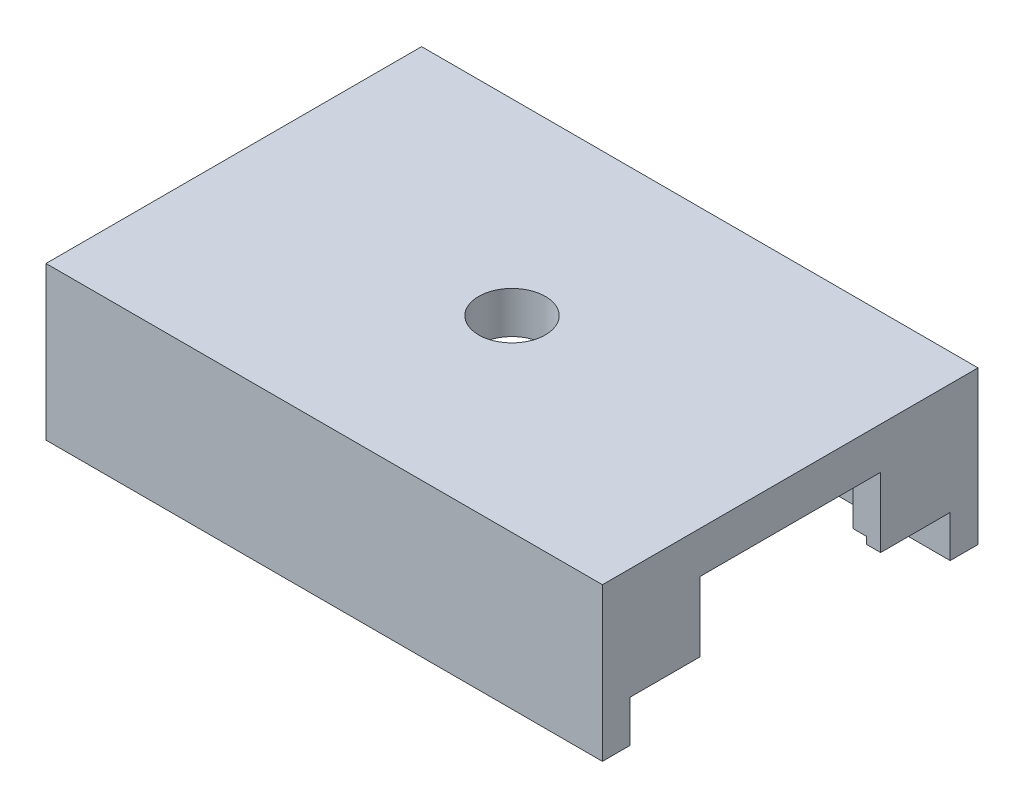
from build123d import *

# Parameters (mm, degrees)
SKETCH3_W           = 40
SKETCH3_H           = 40
SKETCH3_R           = 5
SKETCH3_R_2         = 2.4
BOSS_EXTRUDE2_DEPTH = 3
BOSS_EXTRUDE3_DEPTH = 8
SKETCH6_W           = 2
SKETCH6_H           = 5
BOSS_EXTRUDE5_DEPTH = 5
SKETCH7_W           = 40
SKETCH7_H           = 6.5
CUT_EXTRUDE1_DEPTH  = 3
SKETCH8_W           = 40
SKETCH8_H           = 6.5
CUT_EXTRUDE2_DEPTH  = 3
CUT_EXTRUDE3_START  = -1
SKETCH5_W           = 5
SKETCH5_H           = 0.5
CUT_EXTRUDE3_DEPTH  = 6


with BuildPart() as part:
    # Sketch3 → Boss-Extrude2 (new body)
    with BuildSketch(Plane(origin=(0, 0, 0), x_dir=(1, 0, 0), z_dir=(0, 1, 0))):
        Rectangle(SKETCH3_W, SKETCH3_H)
        Circle(SKETCH3_R, mode=Mode.SUBTRACT)
        Circle(SKETCH3_R)
        Circle(SKETCH3_R_2, mode=Mode.SUBTRACT)
    extrude(amount=-BOSS_EXTRUDE2_DEPTH)

    # Sketch4 → Boss-Extrude3 (add)
    with BuildSketch(Plane.XZ.offset(3)):
        Polygon((20, -11.5), (0, -11.5), (-20, -11.5), (-20, -13.5), (20, -13.5), align=None)
        Polygon((-20, 11.5), (0, 11.5), (20, 11.5), (20, 13.5), (-20, 13.5), align=None)
    extrude(amount=BOSS_EXTRUDE3_DEPTH)

    # Sketch6 → Boss-Extrude5 (add)
    with BuildSketch(Plane.XZ.offset(3)):
        with Locations((19, 9)):
            Rectangle(SKETCH6_W, SKETCH6_H)
        with Locations((19, -9)):
            Rectangle(SKETCH6_W, SKETCH6_H)
        with Locations((-19, -9)):
            Rectangle(SKETCH6_W, SKETCH6_H)
        with Locations((-19, 9)):
            Rectangle(SKETCH6_W, SKETCH6_H)
    extrude(amount=BOSS_EXTRUDE5_DEPTH)

    # Sketch7 → Cut-Extrude1 (cut)
    with BuildSketch(Plane(origin=(0, -3, 0), x_dir=(-1, 0, 0), z_dir=(0, -1, 0))):
        with Locations((0, -16.75)):
            Rectangle(SKETCH7_W, SKETCH7_H)
    extrude(amount=-CUT_EXTRUDE1_DEPTH, mode=Mode.SUBTRACT)

    # Sketch8 → Cut-Extrude2 (cut)
    with BuildSketch(Plane.XZ.offset(3)):
        with Locations((0, -16.75)):
            Rectangle(SKETCH8_W, SKETCH8_H)
    extrude(amount=-CUT_EXTRUDE2_DEPTH, mode=Mode.SUBTRACT)

    # Sketch5 → Cut-Extrude3 (cut)
    with BuildSketch(Plane.XY.offset(-11.5).offset(CUT_EXTRUDE3_START)):
        Polygon((19, -7.5), (0, -7.5), (0, -8), (5, -8), (5, -8.5), (19, -8.5), align=None)
        Polygon((0, -8), (0, -7.5), (-19, -7.5), (-19, -8.5), (-5, -8.5), (-5, -8), align=None)
        with Locations((-2.5, -8.25)):
            Rectangle(SKETCH5_W, SKETCH5_H)
        with Locations((2.5, -8.25)):
            Rectangle(SKETCH5_W, SKETCH5_H)
    cut_extrude3 = extrude(amount=CUT_EXTRUDE3_DEPTH, mode=Mode.SUBTRACT)

    # Mirror2: Cut-Extrude3 across plane
    add(cut_extrude3.mirror(Plane.XY), mode=Mode.SUBTRACT)


solid = part.part
